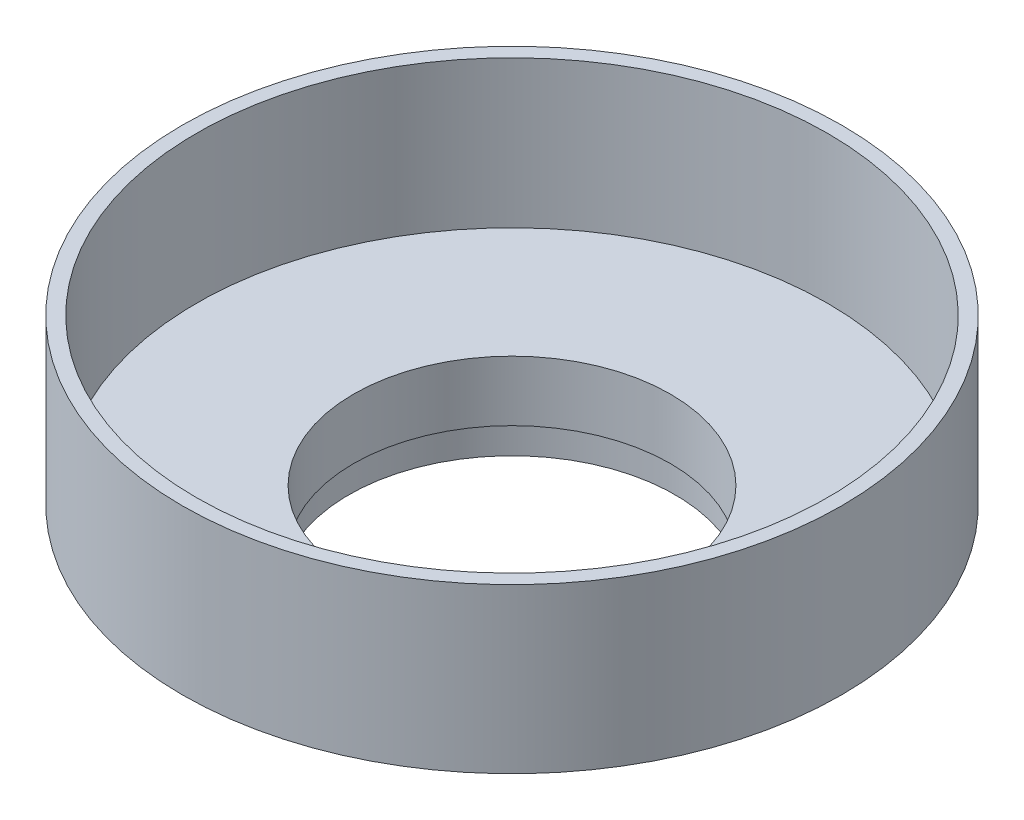
from build123d import *


with BuildPart() as part:
    # Sketch1 → Revolve1 (revolve)
    with BuildSketch(Plane.XY):
        Polygon((34.163, -31.75867376), (34.163, -44.73807376), (35.186931855, -44.73807376), (35.186931855, -51.08807376), (35.556364849, -51.08807376), (35.556364849, -44.48407376), (34.762366334, -44.48407376), (34.762366334, -36.22305653), (68.654205545, -36.22305653), (71.12, -35.325580745), (71.12, 0), (68.072, 0), (68.072, -31.75867376), align=None)
    revolve(axis=Axis((0, 0, 0), (0, -1, 0)))


solid = part.part
